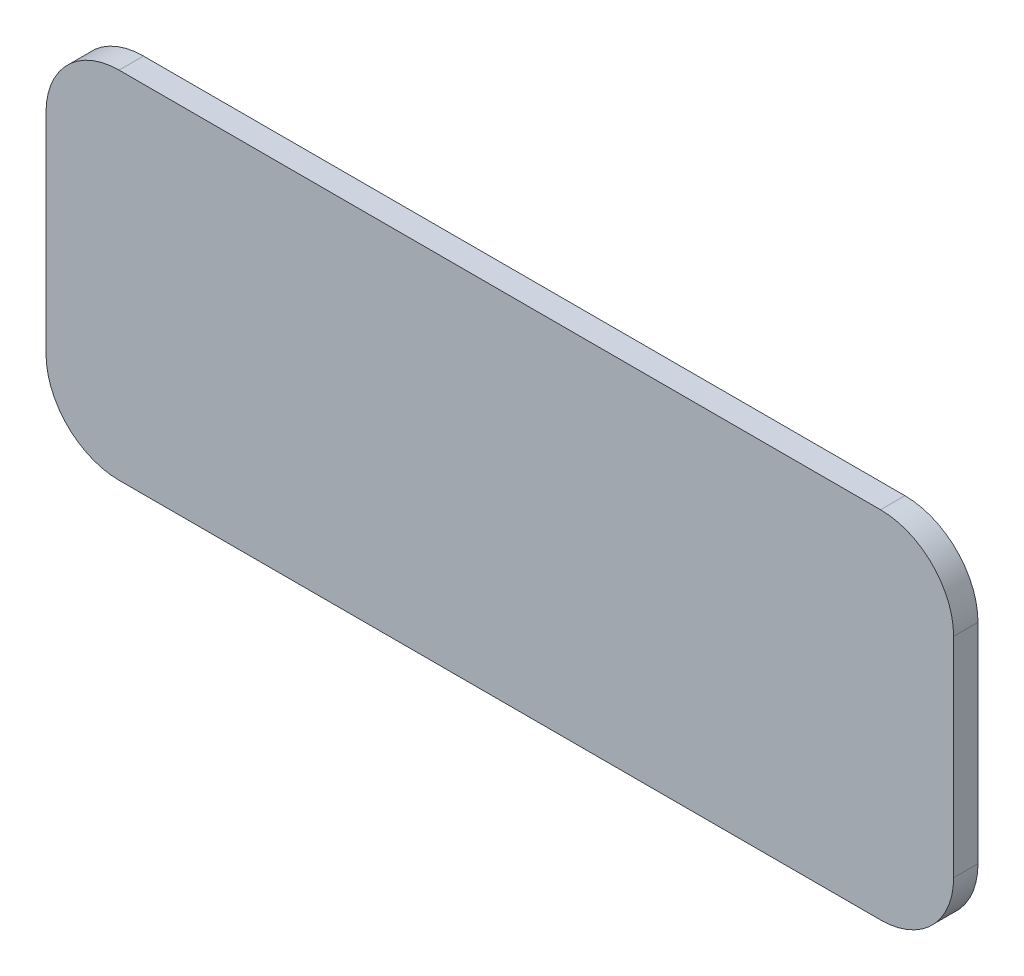
from build123d import *

# Parameters (mm, degrees)
BOSS_EXTRUDE1_DEPTH = 6


with BuildPart() as part:
    # Sketch1 → Boss-Extrude1 (new body)
    with BuildSketch(Plane.XY):
        with BuildLine():
            Line((-268.5, -17.5), (-268.5, 33.98247508))
            ThreePointArc((-268.5, 33.98247508), (-263.227922061, 46.710397141), (-250.5, 51.98247508))
            Line((-250.5, 51.98247508), (-62.991811867, 51.98247508))
            ThreePointArc((-62.991811867, 51.98247508), (-50.263889805, 46.710397141), (-44.991811867, 33.98247508))
            Line((-44.991811867, 33.98247508), (-44.991811867, -17.5))
            ThreePointArc((-44.991811867, -17.5), (-50.263889805, -30.227922061), (-62.991811867, -35.5))
            Line((-62.991811867, -35.5), (-250.5, -35.5))
            ThreePointArc((-250.5, -35.5), (-263.227922061, -30.227922061), (-268.5, -17.5))
        make_face()
    extrude(amount=BOSS_EXTRUDE1_DEPTH)


solid = part.part
